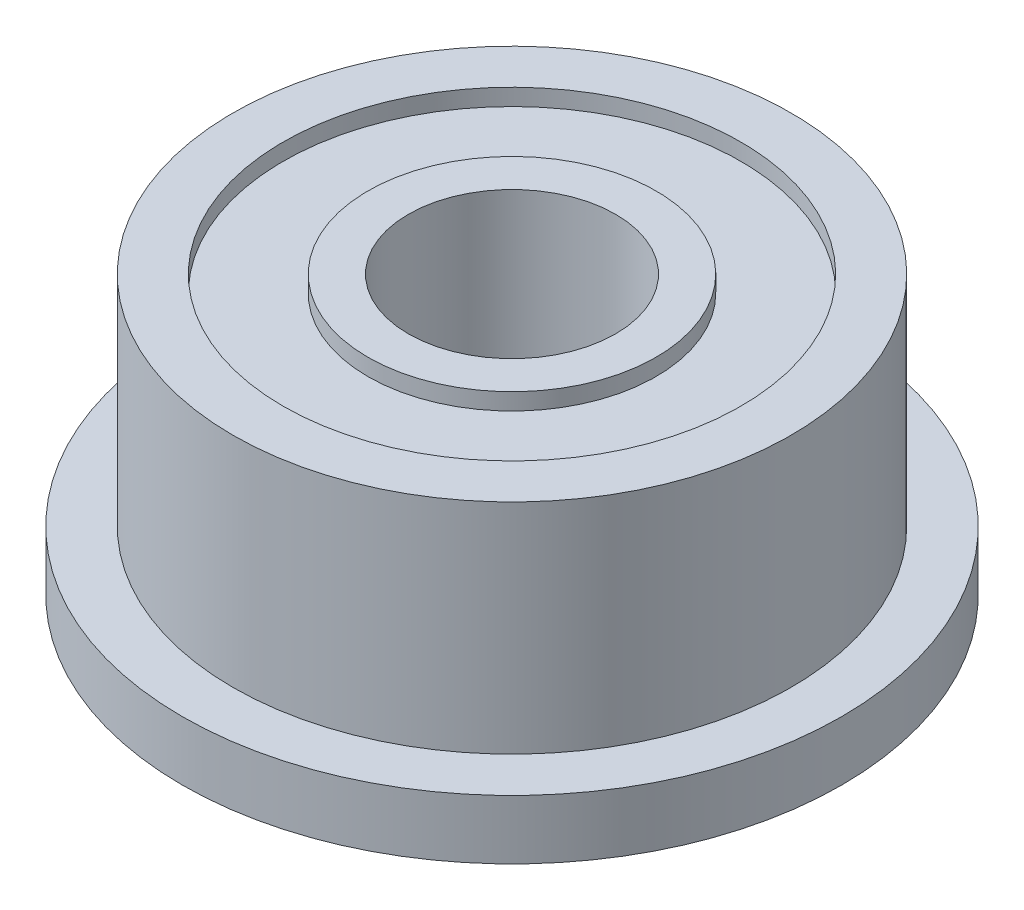
from build123d import *


with BuildPart() as part:
    # Sketch1 → Revolve1 (revolve)
    with BuildSketch(Plane(origin=(0, 0, 0), x_dir=(-1, 0, 0), z_dir=(0, 0, -1))):
        Polygon((-2.065, 0.24), (-2.065, 0), (-1.485, 0), (-1.485, 3.98), (-2.065, 3.98), (-2.065, 3.74), (-3.28, 3.74), (-3.28, 3.98), (-4, 3.98), (-4, 0.85), (-4.725, 0.85), (-4.725, 0), (-3.28, 0), (-3.28, 0.24), align=None)
    revolve(axis=Axis((0, 0, 0), (0, 1, 0)))


solid = part.part
